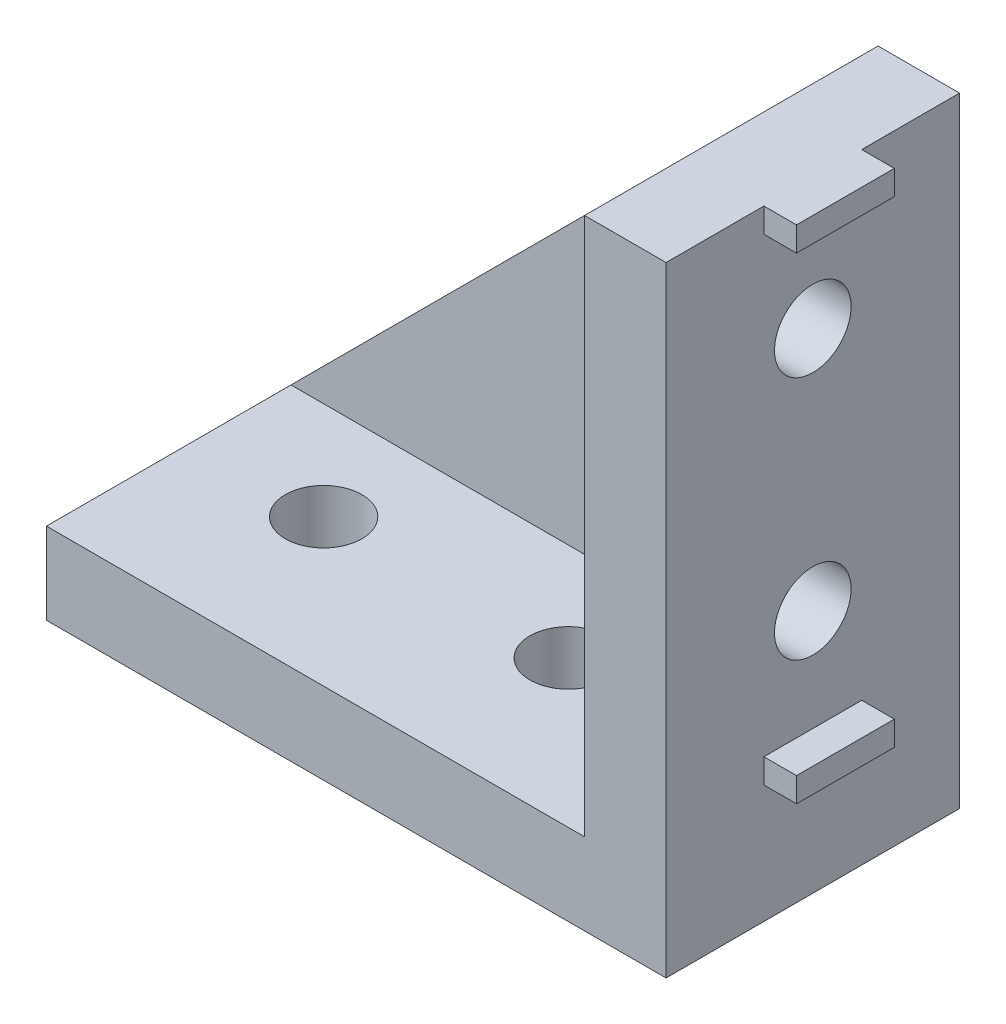
from build123d import *

# Parameters (mm, degrees)
BOSS_EXTRUDE1_DEPTH = 18
SKETCH2_R           = 2.35
CUT_EXTRUDE1_DEPTH  = 18
SKETCH4_W           = 1.5
SKETCH4_H           = 6
BOSS_EXTRUDE3_DEPTH = 2
BOSS_EXTRUDE2_DEPTH = 3


with BuildPart() as part:
    # Sketch1 → Boss-Extrude1 (new body)
    with BuildSketch(Plane.XY):
        Polygon((0, 0), (-38, 0), (-38, 5), (-5, 5), (-5, 38), (0, 38), align=None)
    extrude(amount=BOSS_EXTRUDE1_DEPTH)

    # Sketch2 → Cut-Extrude1 (cut)
    with BuildSketch(Plane(origin=(0, 5, 0), x_dir=(1, 0, 0), z_dir=(0, 1, 0))):
        with Locations((-30, -9)):
            Circle(SKETCH2_R)
        with Locations((-15, -9)):
            Circle(SKETCH2_R)
    cut_extrude1 = extrude(amount=-CUT_EXTRUDE1_DEPTH, mode=Mode.SUBTRACT)

    # Sketch4 → Boss-Extrude3 (add)
    with BuildSketch(Plane.XZ):
        with Locations((-37.25, 9)):
            Rectangle(SKETCH4_W, SKETCH4_H)
        with Locations((-8, 9)):
            Rectangle(SKETCH4_W, SKETCH4_H)
    boss_extrude3 = extrude(amount=BOSS_EXTRUDE3_DEPTH)

    # Mirror1: Cut-Extrude1, Boss-Extrude3 across plane
    add(cut_extrude1.mirror(Plane(origin=(0, 0, 0), x_dir=(0, 0, 1), z_dir=(0.707106781, 0.707106781, 0))), mode=Mode.SUBTRACT)
    add(boss_extrude3.mirror(Plane(origin=(0, 0, 0), x_dir=(0, 0, 1), z_dir=(0.707106781, 0.707106781, 0))))

    # Sketch3 → Boss-Extrude2 (add)
    with BuildSketch(Plane(origin=(0, 0, 0), x_dir=(-1, 0, 0), z_dir=(0, 0, -1))):
        Polygon((5, 38), (38, 5), (5, 5), align=None)
    extrude(amount=-BOSS_EXTRUDE2_DEPTH)


solid = part.part
